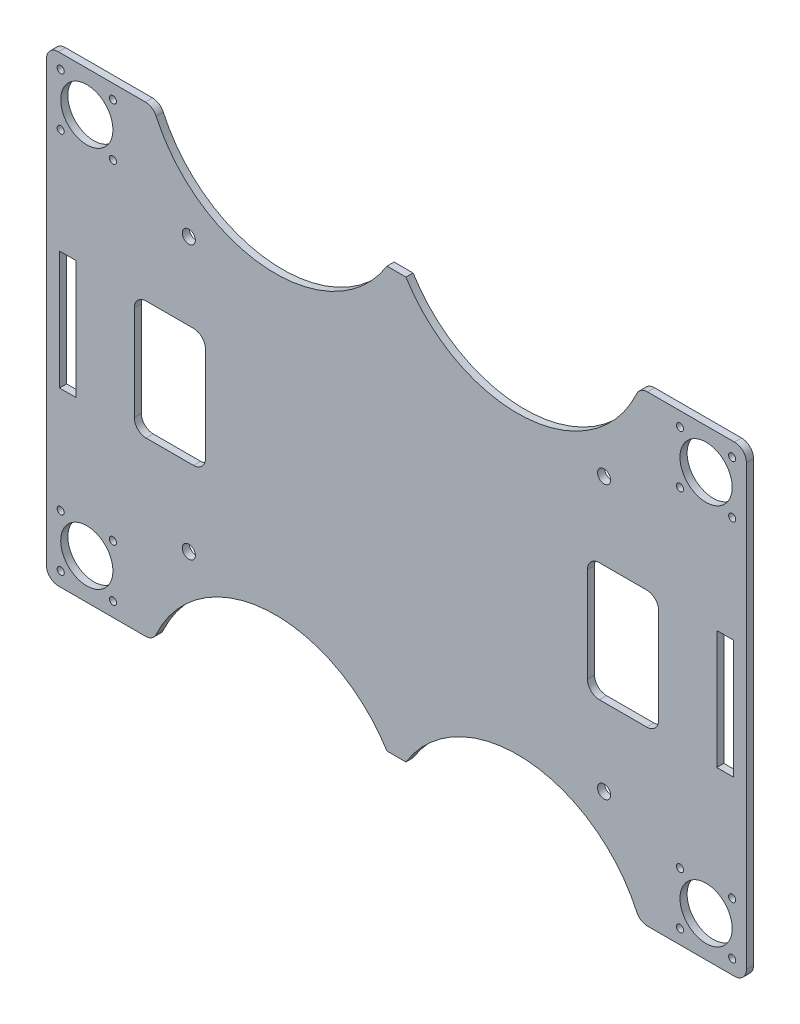
from build123d import *

# Parameters (mm, degrees)
ESQUISSE1_R        = 2.75
ESQUISSE1_R_2      = 11
ESQUISSE1_R_3      = 1.5
ESQUISSE1_W        = 7
ESQUISSE1_H        = 50
BOSS_EXTRU_1_DEPTH = 3


with BuildPart() as part:
    # Esquisse1 → Boss.-Extru.1 (new body)
    with BuildSketch(Plane.XY):
        with BuildLine():
            Line((5, 0), (41.684938398, 0))
            ThreePointArc((41.684938398, 0), (44.389031178, -0.794303597), (46.23397571, -2.924847105))
            ThreePointArc((46.23397571, -2.924847105), (93.045262331, -35.129096737), (143.5, -9))
            Line((143.5, -9), (151.5, -9))
            ThreePointArc((151.5, -9), (201.954737669, -35.129096737), (248.76602429, -2.924847105))
            ThreePointArc((248.76602429, -2.924847105), (250.610968822, -0.794303597), (253.315061602, 0))
            Line((253.315061602, 0), (290, 0))
            ThreePointArc((290, 0), (293.535533906, -1.464466094), (295, -5))
            Line((295, -5), (295, -190))
            ThreePointArc((295, -190), (293.535533906, -193.535533906), (290, -195))
            Line((290, -195), (253.315061602, -195))
            ThreePointArc((253.315061602, -195), (250.610968822, -194.205696403), (248.76602429, -192.075152895))
            ThreePointArc((248.76602429, -192.075152895), (201.954737669, -159.870903263), (151.5, -186))
            Line((151.5, -186), (143.5, -186))
            ThreePointArc((143.5, -186), (93.045262331, -159.870903263), (46.23397571, -192.075152895))
            ThreePointArc((46.23397571, -192.075152895), (44.389031178, -194.205696403), (41.684938398, -195))
            Line((41.684938398, -195), (5, -195))
            ThreePointArc((5, -195), (1.464466094, -193.535533906), (0, -190))
            Line((0, -190), (0, -5))
            ThreePointArc((0, -5), (1.464466094, -1.464466094), (5, 0))
        make_face()
        with Locations((60, -40)):
            Circle(ESQUISSE1_R, mode=Mode.SUBTRACT)
        with Locations((17, -17.00000759)):
            Circle(ESQUISSE1_R_2, mode=Mode.SUBTRACT)
        with Locations((6, -6.00000759)):
            Circle(ESQUISSE1_R_3, mode=Mode.SUBTRACT)
        with Locations((28, -6.00000759)):
            Circle(ESQUISSE1_R_3, mode=Mode.SUBTRACT)
        with Locations((28, -28.00000759)):
            Circle(ESQUISSE1_R_3, mode=Mode.SUBTRACT)
        with Locations((6, -28.00000759)):
            Circle(ESQUISSE1_R_3, mode=Mode.SUBTRACT)
        with Locations((235, -40)):
            Circle(ESQUISSE1_R, mode=Mode.SUBTRACT)
        with Locations((289, -6.00000759)):
            Circle(ESQUISSE1_R_3, mode=Mode.SUBTRACT)
        with Locations((267, -6.00000759)):
            Circle(ESQUISSE1_R_3, mode=Mode.SUBTRACT)
        with Locations((278, -17.00000759)):
            Circle(ESQUISSE1_R_2, mode=Mode.SUBTRACT)
        with Locations((289, -28.00000759)):
            Circle(ESQUISSE1_R_3, mode=Mode.SUBTRACT)
        with Locations((267, -28.00000759)):
            Circle(ESQUISSE1_R_3, mode=Mode.SUBTRACT)
        with Locations((267, -188.99999241)):
            Circle(ESQUISSE1_R_3, mode=Mode.SUBTRACT)
        with Locations((289, -188.99999241)):
            Circle(ESQUISSE1_R_3, mode=Mode.SUBTRACT)
        with Locations((289, -166.99999241)):
            Circle(ESQUISSE1_R_3, mode=Mode.SUBTRACT)
        with Locations((267, -166.99999241)):
            Circle(ESQUISSE1_R_3, mode=Mode.SUBTRACT)
        with Locations((278, -177.99999241)):
            Circle(ESQUISSE1_R_2, mode=Mode.SUBTRACT)
        with Locations((235, -155)):
            Circle(ESQUISSE1_R, mode=Mode.SUBTRACT)
        with Locations((60, -155)):
            Circle(ESQUISSE1_R, mode=Mode.SUBTRACT)
        with Locations((6, -188.99999241)):
            Circle(ESQUISSE1_R_3, mode=Mode.SUBTRACT)
        with Locations((28, -188.99999241)):
            Circle(ESQUISSE1_R_3, mode=Mode.SUBTRACT)
        with Locations((17, -177.99999241)):
            Circle(ESQUISSE1_R_2, mode=Mode.SUBTRACT)
        with Locations((6, -166.99999241)):
            Circle(ESQUISSE1_R_3, mode=Mode.SUBTRACT)
        with Locations((28, -166.99999241)):
            Circle(ESQUISSE1_R_3, mode=Mode.SUBTRACT)
        with BuildLine():
            Line((228, -77.5), (228, -117.5))
            ThreePointArc((228, -117.5), (229.464466094, -121.035533906), (233, -122.5))
            Line((233, -122.5), (253, -122.5))
            ThreePointArc((253, -122.5), (256.535533906, -121.035533906), (258, -117.5))
            Line((258, -117.5), (258, -77.5))
            ThreePointArc((258, -77.5), (256.535533906, -73.964466094), (253, -72.5))
            Line((253, -72.5), (233, -72.5))
            ThreePointArc((233, -72.5), (229.464466094, -73.964466094), (228, -77.5))
        make_face(mode=Mode.SUBTRACT)
        with BuildLine():
            Line((42, -72.5), (62, -72.5))
            ThreePointArc((62, -72.5), (65.535533906, -73.964466094), (67, -77.5))
            Line((67, -77.5), (67, -117.5))
            ThreePointArc((67, -117.5), (65.535533906, -121.035533906), (62, -122.5))
            Line((62, -122.5), (42, -122.5))
            ThreePointArc((42, -122.5), (38.464466094, -121.035533906), (37, -117.5))
            Line((37, -117.5), (37, -77.5))
            ThreePointArc((37, -77.5), (38.464466094, -73.964466094), (42, -72.5))
        make_face(mode=Mode.SUBTRACT)
        with Locations((286, -97.5)):
            Rectangle(ESQUISSE1_W, ESQUISSE1_H, mode=Mode.SUBTRACT)
        with Locations((9, -97.5)):
            Rectangle(ESQUISSE1_W, ESQUISSE1_H, mode=Mode.SUBTRACT)
    extrude(amount=BOSS_EXTRU_1_DEPTH)


solid = part.part
